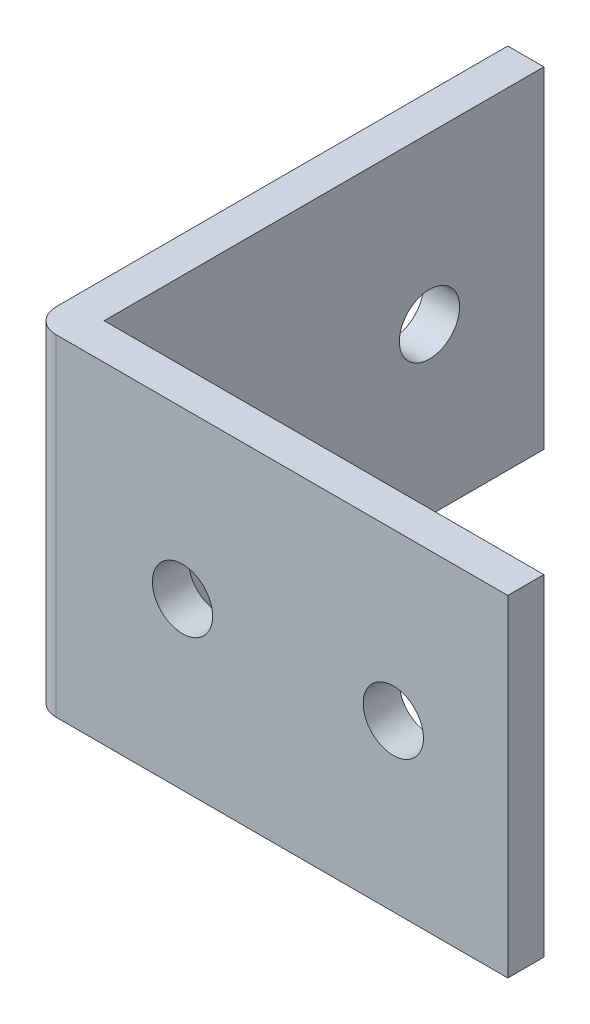
from build123d import *

# Parameters (mm, degrees)
SKETCH1_W           = 39.5
SKETCH1_H           = 27.5
SKETCH1_R           = 2.5
BOSS_EXTRUDE1_DEPTH = 3
SKETCH3_W           = 3
SKETCH3_H           = 27.5
BOSS_EXTRUDE2_DEPTH = 36.5
SKETCH4_R           = 2.5
CUT_EXTRUDE1_DEPTH  = 36.5
FILLET1_R           = 2


with BuildPart() as part:
    # Sketch1 → Boss-Extrude1 (new body)
    with BuildSketch(Plane.XY):
        with Locations((-17.382808989, -12.897191011)):
            Rectangle(SKETCH1_W, SKETCH1_H)
        with Locations((-24.632808989, -12.897191011)):
            Circle(SKETCH1_R, mode=Mode.SUBTRACT)
        with Locations((-7.132808989, -12.897191011)):
            Circle(SKETCH1_R, mode=Mode.SUBTRACT)
    extrude(amount=BOSS_EXTRUDE1_DEPTH)

    # Sketch3 → Boss-Extrude2 (add)
    with BuildSketch(Plane(origin=(0, 0, 0), x_dir=(-1, 0, 0), z_dir=(0, 0, -1))):
        with Locations((35.632808989, -12.897191011)):
            Rectangle(SKETCH3_W, SKETCH3_H)
    extrude(amount=BOSS_EXTRUDE2_DEPTH)

    # Sketch4 → Cut-Extrude1 (cut)
    with BuildSketch(Plane(origin=(-34.132808989, 0, 0), x_dir=(0, 0, -1), z_dir=(1, 0, 0))):
        with Locations((9.5, -12.897191011)):
            Circle(SKETCH4_R)
        with Locations((27, -12.897191011)):
            Circle(SKETCH4_R)
    extrude(amount=-CUT_EXTRUDE1_DEPTH, mode=Mode.SUBTRACT)

    # Fillet1
    fillet1_edges = [part.edges().sort_by_distance(p)[0] for p in [
        (-37.132808989, -12.897191011, 3),
    ]]
    fillet(fillet1_edges, radius=FILLET1_R)


solid = part.part
